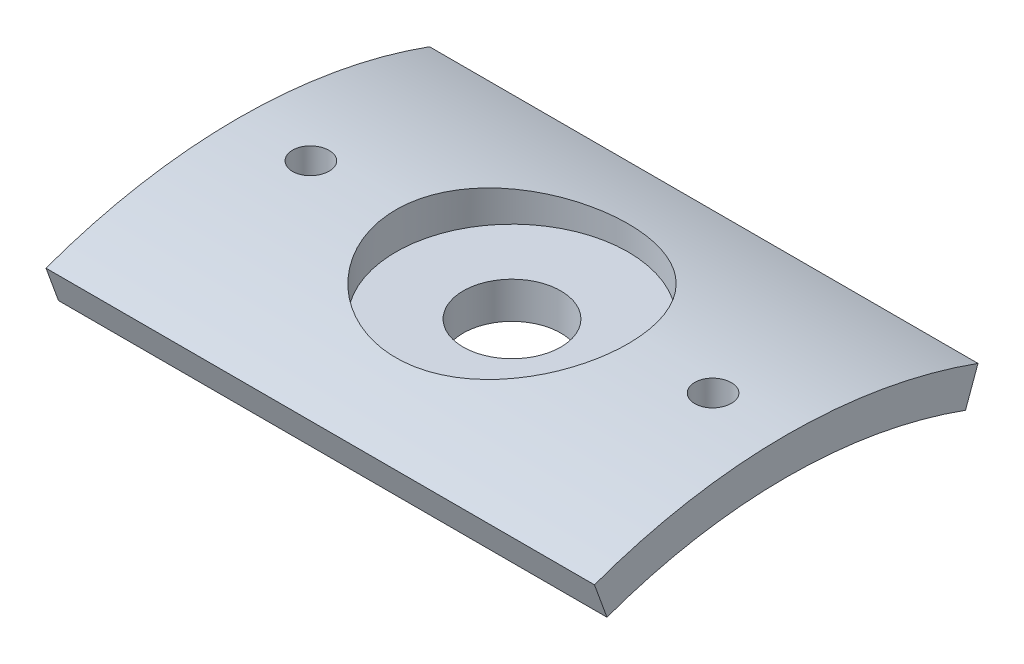
from build123d import *

# Parameters (mm, degrees)
BOSS_EXTRUDE1_DEPTH     = 45
SKETCH2_R               = 12.5
BOSS_EXTRUDE2_DEPTH     = 3
SKETCH3_R               = 9.525
CUT_EXTRUDE1_DEPTH      = 14
SKETCH4_R               = 4
CUT_EXTRUDE2_DEPTH      = 14
CUT_EXTRUDE3_DEPTH      = 14
CUT_EXTRUDE3_DEPTH_BACK = 14
SKETCH5_R               = 1.5


with BuildPart() as part:
    # Sketch1 → Boss-Extrude1 (new body)
    with BuildSketch(Plane(origin=(0, 0, 0), x_dir=(0, 0, -1), z_dir=(1, 0, 0))):
        with BuildLine():
            Line((-14.706866163, -5.593217306), (-15.732926593, -2.774139444))
            ThreePointArc((-15.732926593, -2.774139444), (0, 0), (15.732926593, -2.774139444))
            Line((15.732926593, -2.774139444), (14.706866163, -5.593217306))
            ThreePointArc((14.706866163, -5.593217306), (0, -3), (-14.706866163, -5.593217306))
        make_face()
    extrude(amount=BOSS_EXTRUDE1_DEPTH)

    # Sketch2 → Boss-Extrude2 (add)
    with BuildSketch(Plane(origin=(0, -3, 0), x_dir=(1, 0, 0), z_dir=(0, 1, 0))):
        with Locations((22.5, 0)):
            Circle(SKETCH2_R)
    extrude(amount=-BOSS_EXTRUDE2_DEPTH)

    # Sketch3 → Cut-Extrude1 (cut)
    with BuildSketch(Plane(origin=(0, -3, 0), x_dir=(1, 0, 0), z_dir=(0, 1, 0))):
        with Locations((22.5, 0)):
            Circle(SKETCH3_R)
    extrude(amount=CUT_EXTRUDE1_DEPTH, mode=Mode.SUBTRACT)

    # Sketch4 → Cut-Extrude2 (cut)
    with BuildSketch(Plane(origin=(0, -3, 0), x_dir=(1, 0, 0), z_dir=(0, 1, 0))):
        with Locations((22.5, 0)):
            Circle(SKETCH4_R)
    extrude(amount=-CUT_EXTRUDE2_DEPTH, mode=Mode.SUBTRACT)

    # Sketch5 → Cut-Extrude3 (cut, two sides: drawn at the far end of the back side and taken through both)
    with BuildSketch(Plane(origin=(0, -3, 0), x_dir=(1, 0, 0), z_dir=(0, 1, 0)).offset(-CUT_EXTRUDE3_DEPTH_BACK)):
        with Locations((6, 0)):
            Circle(SKETCH5_R)
        with Locations((39, 0)):
            Circle(SKETCH5_R)
    extrude(amount=CUT_EXTRUDE3_DEPTH + CUT_EXTRUDE3_DEPTH_BACK, mode=Mode.SUBTRACT)


solid = part.part
